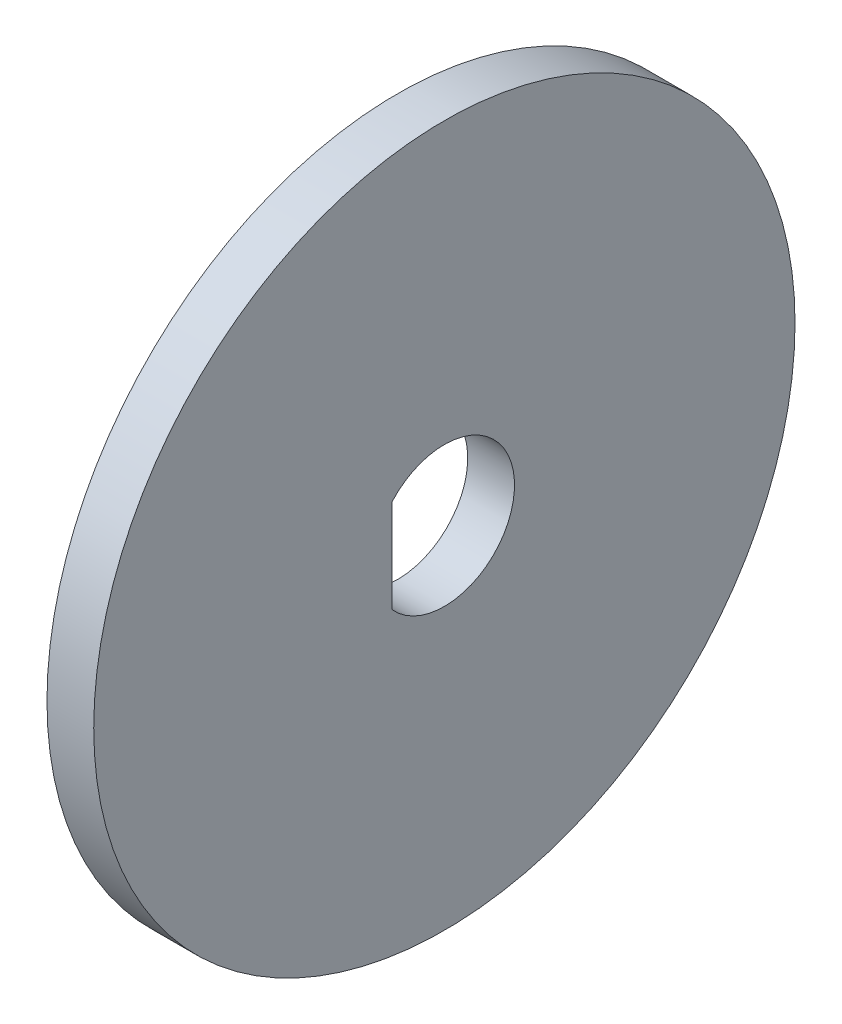
from build123d import *

# Parameters (mm, degrees)
SKETCH1_R           = 15
BOSS_EXTRUDE1_DEPTH = 2
CUT_EXTRUDE1_DEPTH  = 3


with BuildPart() as part:
    # Sketch1 → Boss-Extrude1 (new body)
    with BuildSketch(Plane(origin=(0, 0, 0), x_dir=(0, 0, -1), z_dir=(1, 0, 0))):
        Circle(SKETCH1_R)
    extrude(amount=BOSS_EXTRUDE1_DEPTH)

    # Sketch2 → Cut-Extrude1 (cut, through all)
    with BuildSketch(Plane(origin=(2, 0, 0), x_dir=(0, 0, -1), z_dir=(1, 0, 0))):
        with BuildLine():
            Line((-2.236067977, 2), (-2.236067977, -2))
            ThreePointArc((-2.236067977, -2), (3, 0), (-2.236067977, 2))
        make_face()
    extrude(amount=-CUT_EXTRUDE1_DEPTH, mode=Mode.SUBTRACT)


solid = part.part
